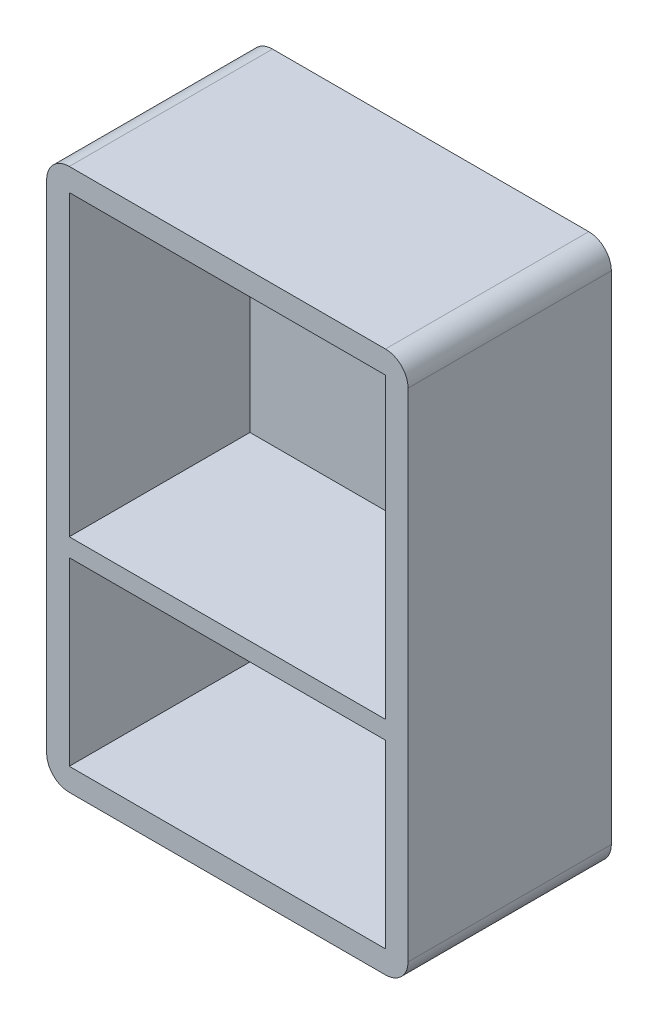
from build123d import *

# Parameters (mm, degrees)
SKETCH1_W           = 80
SKETCH1_H           = 120
BOSS_EXTRUDE1_DEPTH = 5
SKETCH2_W           = 80
SKETCH2_H           = 120
SKETCH2_W_2         = 70
SKETCH2_H_2         = 66
SKETCH2_H_3         = 40
BOSS_EXTRUDE2_DEPTH = 40
FILLET1_R           = 5


with BuildPart() as part:
    # Sketch1 → Boss-Extrude1 (new body)
    with BuildSketch(Plane.XY):
        Rectangle(SKETCH1_W, SKETCH1_H)
    extrude(amount=BOSS_EXTRUDE1_DEPTH)

    # Sketch2 → Boss-Extrude2 (add)
    with BuildSketch(Plane.XY.offset(5)):
        Rectangle(SKETCH2_W, SKETCH2_H)
        with Locations((0, 22)):
            Rectangle(SKETCH2_W_2, SKETCH2_H_2, mode=Mode.SUBTRACT)
        with Locations((0, -35)):
            Rectangle(SKETCH2_W_2, SKETCH2_H_3, mode=Mode.SUBTRACT)
    extrude(amount=BOSS_EXTRUDE2_DEPTH)

    # Fillet1
    fillet1_edges = [part.edges().sort_by_distance(p)[0] for p in [
        (40, -60, 22.5),
        (-40, -60, 22.5),
        (-40, 60, 22.5),
        (40, 60, 22.5),
    ]]
    fillet(fillet1_edges, radius=FILLET1_R)


solid = part.part
